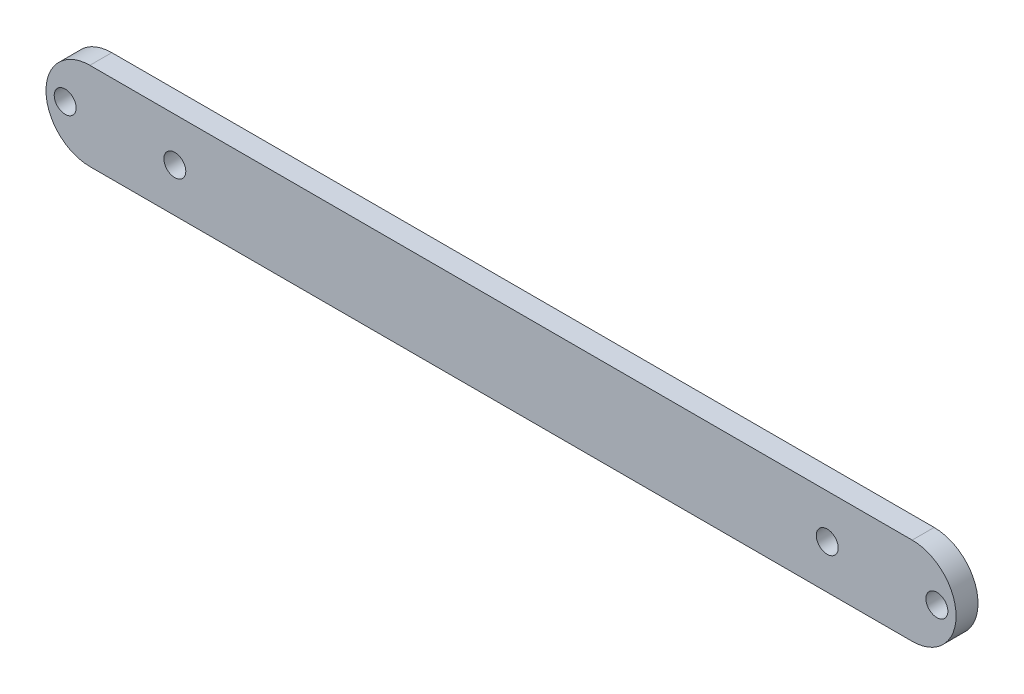
from build123d import *

# Parameters (mm, degrees)
EXTRUDE_1_DEPTH     = 4
SKETCH_2_R          = 2
CUT_EXTRUDE_1_DEPTH = 10


with BuildPart() as part:
    # 草图1 → 凸台-拉伸1 (new body)
    with BuildSketch(Plane.XY):
        with BuildLine():
            Line((0, 8), (150, 8))
            ThreePointArc((150, 8), (158, 0), (150, -8))
            Line((150, -8), (0, -8))
            ThreePointArc((0, -8), (-8, 0), (0, 8))
        make_face()
    extrude(amount=EXTRUDE_1_DEPTH)

    # 草图2 → 切除-拉伸1 (cut)
    with BuildSketch(Plane.XY.offset(4)):
        with Locations((15.5, 0)):
            Circle(SKETCH_2_R)
        with Locations((134.5, 0)):
            Circle(SKETCH_2_R)
        with Locations((-4.5, 0)):
            Circle(SKETCH_2_R)
        with Locations((154.5, 0)):
            Circle(SKETCH_2_R)
    extrude(amount=-CUT_EXTRUDE_1_DEPTH, mode=Mode.SUBTRACT)


solid = part.part
